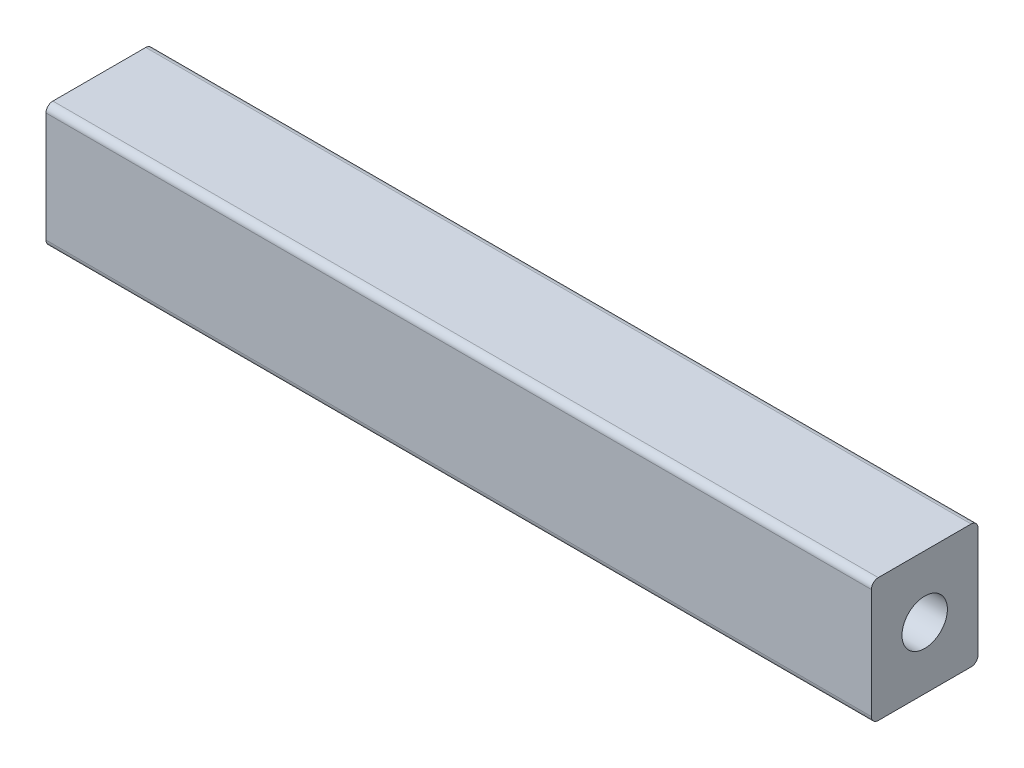
from build123d import *

# Parameters (mm, degrees)
SKETCH1_W           = 15.5
SKETCH1_H           = 18
BOSS_EXTRUDE1_DEPTH = 60
FILLET1_R           = 1


with BuildPart() as part:
    # Sketch1 → Boss-Extrude1 (new body, symmetric)
    with BuildSketch(Plane(origin=(0, 0, 0), x_dir=(0, 0, -1), z_dir=(1, 0, 0))):
        Rectangle(SKETCH1_W, SKETCH1_H)
    extrude(amount=BOSS_EXTRUDE1_DEPTH, both=True)

    # Fillet1
    fillet1_edges = [part.edges().sort_by_distance(p)[0] for p in [
        (0, -9, -7.75),
        (0, -9, 7.75),
        (0, 9, 7.75),
        (0, 9, -7.75),
    ]]
    fillet(fillet1_edges, radius=FILLET1_R)

    # Sketch3 → Ø1.0 (6.6) Diameter Hole1 (revolve, cut)
    with BuildSketch(Plane(origin=(60, 0, 0), x_dir=(0, 0, -1), z_dir=(0, 1, 0))):
        Polygon((0, 0), (0, 13.982840043), (3.3, 12), (3.3, 0), align=None)
    f_1_0_6_6_diameter_hole1 = revolve(axis=Axis((66.35, 0, 0), (-1, 0, 0)), mode=Mode.SUBTRACT)

    # Mirror1: Ø1.0 (6.6) Diameter Hole1 across plane
    add(f_1_0_6_6_diameter_hole1.mirror(Plane(origin=(0, 0, 0), x_dir=(0, 0, 1), z_dir=(1, 0, 0))), mode=Mode.SUBTRACT)


solid = part.part
